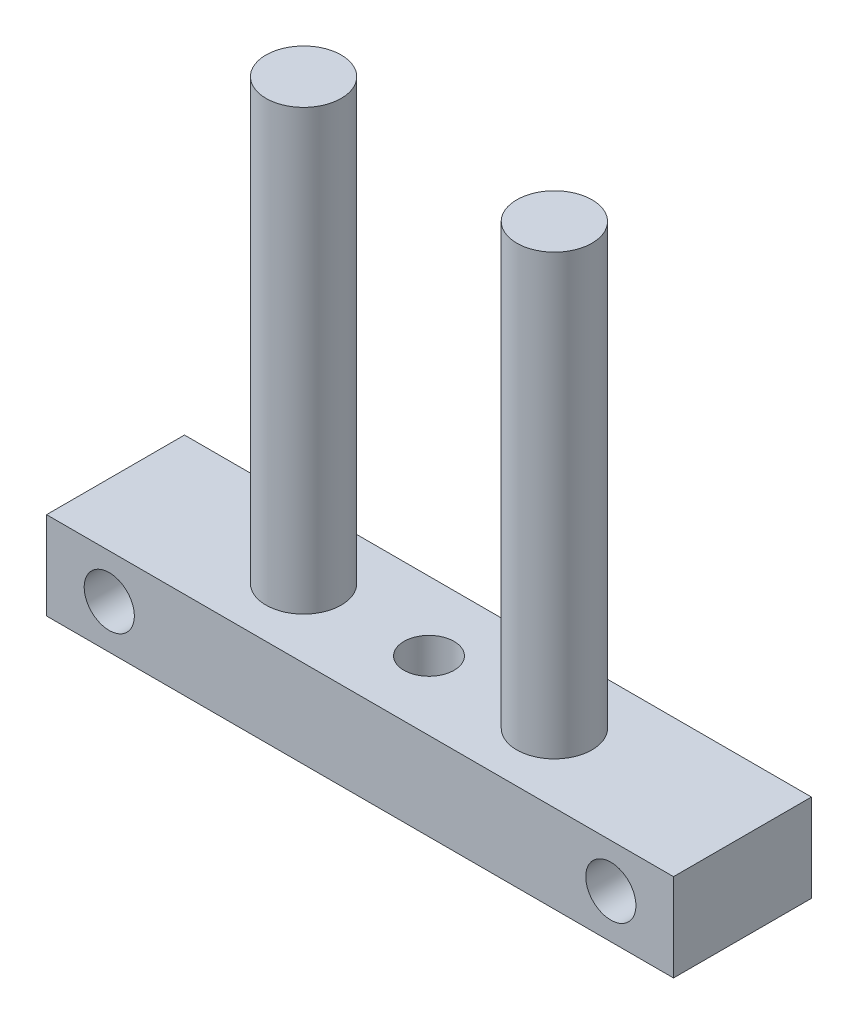
from build123d import *

# Parameters (mm, degrees)
SKETCH1_W           = 50
SKETCH1_H           = 7
BOSS_EXTRUDE1_DEPTH = 11
SKETCH2_R           = 2
CUT_EXTRUDE1_DEPTH  = 12
SKETCH3_R           = 2
CUT_EXTRUDE2_DEPTH  = 8
SKETCH4_R           = 3
BOSS_EXTRUDE2_DEPTH = 35


with BuildPart() as part:
    # Sketch1 → Boss-Extrude1 (new body)
    with BuildSketch(Plane.XY):
        Rectangle(SKETCH1_W, SKETCH1_H)
    extrude(amount=BOSS_EXTRUDE1_DEPTH)

    # Sketch2 → Cut-Extrude1 (cut, through all)
    with BuildSketch(Plane(origin=(0, 0, 0), x_dir=(-1, 0, 0), z_dir=(0, 0, -1))):
        with Locations((20, 0)):
            Circle(SKETCH2_R)
        with Locations((-20, 0)):
            Circle(SKETCH2_R)
    extrude(amount=-CUT_EXTRUDE1_DEPTH, mode=Mode.SUBTRACT)

    # Sketch3 → Cut-Extrude2 (cut, through all)
    with BuildSketch(Plane.XZ.offset(3.5)):
        with Locations((0, 5.5)):
            Circle(SKETCH3_R)
    extrude(amount=-CUT_EXTRUDE2_DEPTH, mode=Mode.SUBTRACT)

    # Sketch4 → Boss-Extrude2 (add)
    with BuildSketch(Plane(origin=(0, 3.5, 0), x_dir=(1, 0, 0), z_dir=(0, 1, 0))):
        with Locations((-10, -5.5)):
            Circle(SKETCH4_R)
        with Locations((10, -5.5)):
            Circle(SKETCH4_R)
    extrude(amount=BOSS_EXTRUDE2_DEPTH)


solid = part.part
